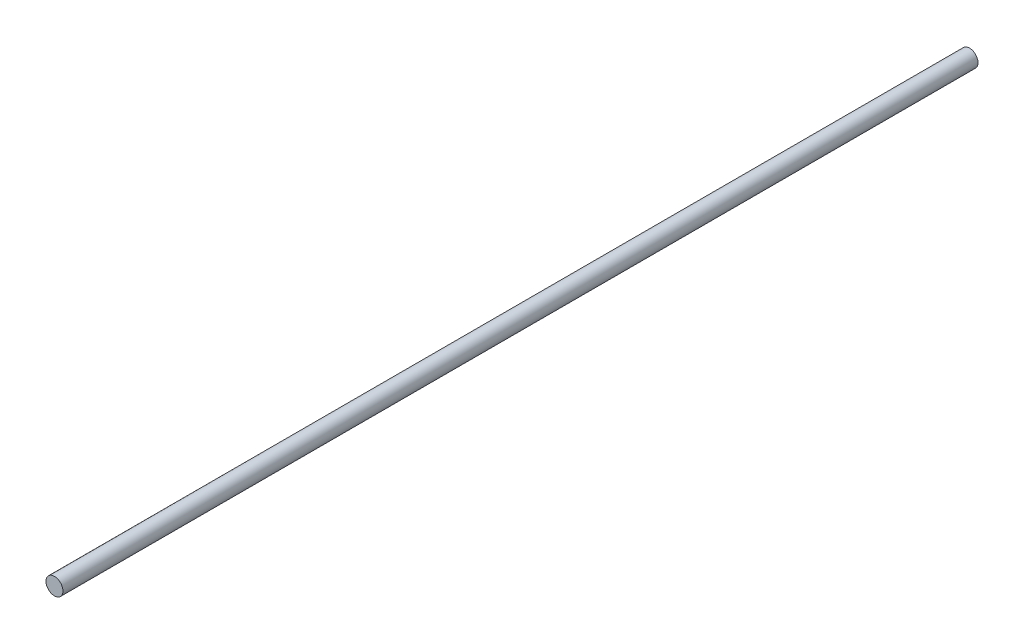
from build123d import *

# Parameters (mm, degrees)
SKETCH1_R           = 3.96875
BOSS_EXTRUDE1_DEPTH = 428.625


with BuildPart() as part:
    # Sketch1 → Boss-Extrude1 (new body)
    with BuildSketch(Plane.XY):
        Circle(SKETCH1_R)
    extrude(amount=BOSS_EXTRUDE1_DEPTH)


solid = part.part
